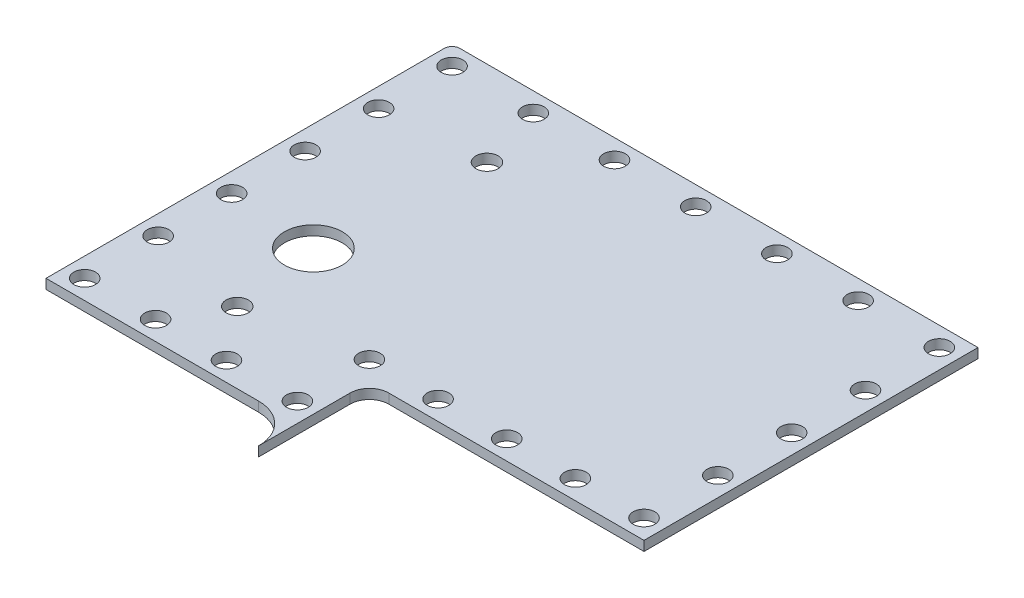
from build123d import *

# Parameters (mm, degrees)
BOSS_EXTRUDE1_DEPTH     = 1.5875
FILLET1_R               = 3.175
SKETCH2_R               = 4.750027573
SKETCH2_R_2             = 1.830008083
CUT_EXTRUDE1_DEPTH      = 1
CUT_EXTRUDE1_DEPTH_BACK = 2.5875
SKETCH3_R               = 1.778
CUT_EXTRUDE2_DEPTH      = 1
CUT_EXTRUDE2_DEPTH_BACK = 2.5875


with BuildPart() as part:
    # Sketch1 → Boss-Extrude1 (new body)
    with BuildSketch(Plane(origin=(0, 0, 0), x_dir=(1, 0, 0), z_dir=(0, 1, 0))):
        with BuildLine():
            Line((-8.89, -66.675), (-43.815, -66.675))
            Line((-43.815, -66.675), (-43.815, -1.27))
            ThreePointArc((-43.815, -1.27), (-43.443025612, -0.371974388), (-42.545, 0))
            Line((-42.545, 0), (42.545, 0))
            Line((42.545, 0), (42.545, -54.843091388))
            Line((42.545, -54.843091388), (-2.54, -54.843091388))
            Line((-2.54, -54.843091388), (-2.54, -73.025))
            ThreePointArc((-2.54, -73.025), (-4.399871939, -68.534871939), (-8.89, -66.675))
        make_face()
    extrude(amount=BOSS_EXTRUDE1_DEPTH)

    # Fillet1
    fillet1_edges = [part.edges().sort_by_distance(p)[0] for p in [
        (-2.54, 0.79375, 54.843091388),
    ]]
    fillet(fillet1_edges, radius=FILLET1_R)

    # Sketch2 → Cut-Extrude1 (cut, two sides)
    with BuildSketch(Plane(origin=(0, 1.5875, 0), x_dir=(-1, 0, 0), z_dir=(0, 1, 0))) as cut_extrude1_sk:
        with Locations((26.115028378, 40.470331632)):
            Circle(SKETCH2_R)
        with Locations((24.115016768, 54.970415803)):
            Circle(SKETCH2_R_2)
        with Locations((24.114889767, 13.97)):
            Circle(SKETCH2_R_2)
    extrude(amount=CUT_EXTRUDE1_DEPTH, mode=Mode.SUBTRACT)
    extrude(cut_extrude1_sk.sketch, amount=-CUT_EXTRUDE1_DEPTH_BACK, mode=Mode.SUBTRACT)

    # Sketch3 → Cut-Extrude2 (cut, two sides)
    with BuildSketch(Plane(origin=(0, 1.5875, 0), x_dir=(-1, 0, 0), z_dir=(0, 1, 0))) as cut_extrude2_sk:
        with Locations((27.305, 3.175)):
            Circle(SKETCH3_R)
        with Locations((13.97, 3.175)):
            Circle(SKETCH3_R)
        with Locations((0.635, 3.175)):
            Circle(SKETCH3_R)
        with Locations((-12.7, 3.175)):
            Circle(SKETCH3_R)
        with Locations((-26.035, 3.175)):
            Circle(SKETCH3_R)
        with Locations((-39.37, 3.175)):
            Circle(SKETCH3_R)
        with Locations((-39.37, 15.298272847)):
            Circle(SKETCH3_R)
        with Locations((-39.37, 27.421545694)):
            Circle(SKETCH3_R)
        with Locations((-39.37, 39.544818541)):
            Circle(SKETCH3_R)
        with Locations((-39.37, 51.668091388)):
            Circle(SKETCH3_R)
        with Locations((-28.09875, 51.668091388)):
            Circle(SKETCH3_R)
        with Locations((-16.8275, 51.668091388)):
            Circle(SKETCH3_R)
        with Locations((-5.55625, 51.668091388)):
            Circle(SKETCH3_R)
        with Locations((5.715, 51.668091388)):
            Circle(SKETCH3_R)
        with Locations((5.715, 63.5)):
            Circle(SKETCH3_R)
        with Locations((17.356666667, 63.5)):
            Circle(SKETCH3_R)
        with Locations((28.998333333, 63.5)):
            Circle(SKETCH3_R)
        with Locations((40.64, 63.5)):
            Circle(SKETCH3_R)
        with Locations((40.64, 51.435)):
            Circle(SKETCH3_R)
        with Locations((40.64, 39.37)):
            Circle(SKETCH3_R)
        with Locations((40.64, 27.305)):
            Circle(SKETCH3_R)
        with Locations((40.64, 15.24)):
            Circle(SKETCH3_R)
        with Locations((40.64, 3.175)):
            Circle(SKETCH3_R)
    extrude(amount=CUT_EXTRUDE2_DEPTH, mode=Mode.SUBTRACT)
    extrude(cut_extrude2_sk.sketch, amount=-CUT_EXTRUDE2_DEPTH_BACK, mode=Mode.SUBTRACT)


solid = part.part
